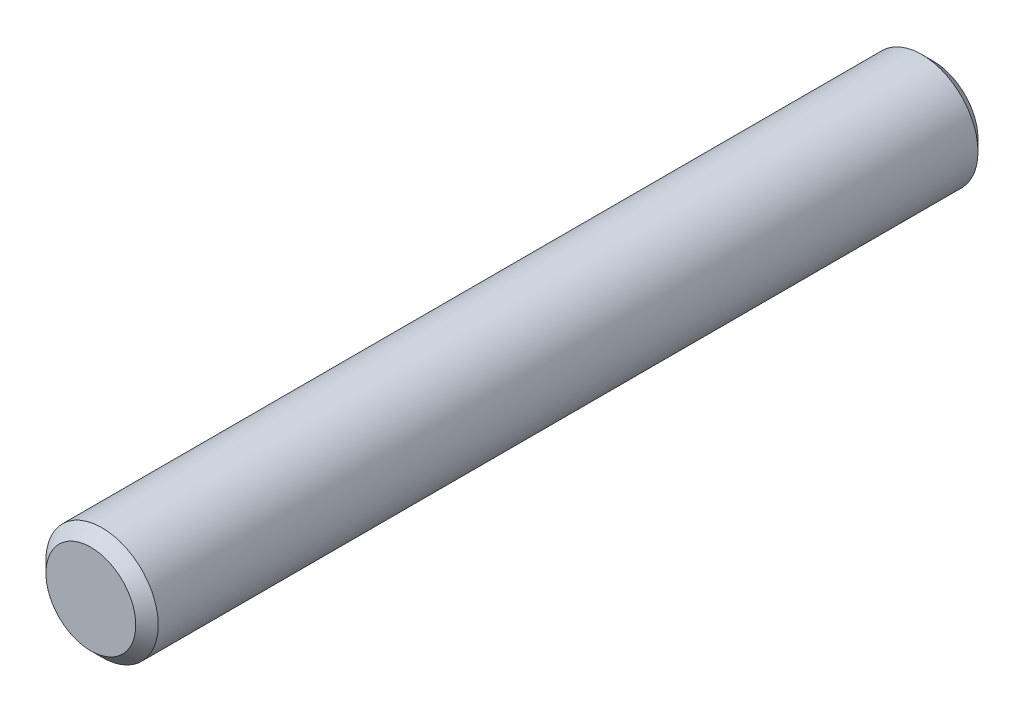
from build123d import *

# Parameters (mm, degrees)
SKETCH_1_R      = 1
EXTRUDE_1_DEPTH = 7.5
CHAMFER_1_SIZE  = 0.2


with BuildPart() as part:
    # 草图1 → 凸台-拉伸1 (new body, symmetric)
    with BuildSketch(Plane.XY):
        Circle(SKETCH_1_R)
    extrude(amount=EXTRUDE_1_DEPTH, both=True)

    # 倒角1
    chamfer_1_edges = [part.edges().sort_by_distance(p)[0] for p in [
        (-1, 0, -7.5),
        (-1, 0, 7.5),
    ]]
    chamfer(chamfer_1_edges, length=CHAMFER_1_SIZE)


solid = part.part
